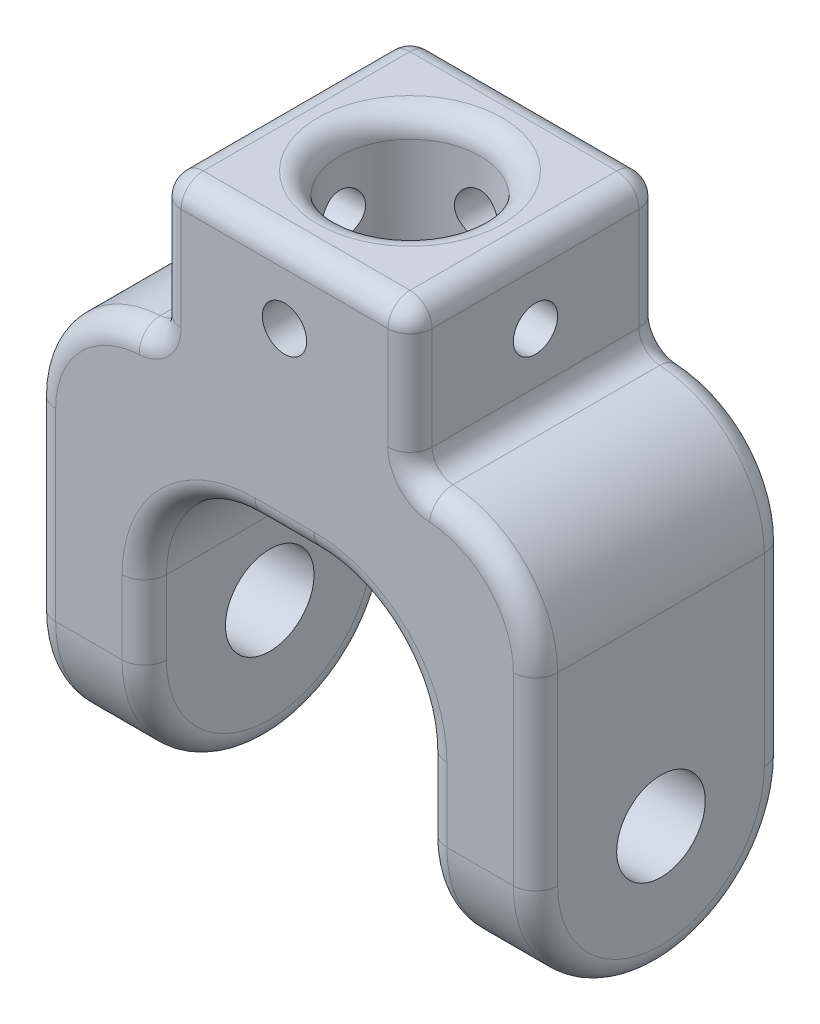
from build123d import *

# Parameters (mm, degrees)
Y_KSEKLIK_EKSTR_ZYON2_DEPTH = 17
IZIM2_R                     = 9.5
KES_EKSTR_ZYON1_DEPTH       = 77.866068747
KES_EKSTR_ZYON2_DEPTH       = 69
IZIM4_R                     = 6
KES_EKSTR_ZYON3_DEPTH       = 69
IZIM5_R                     = 3
KES_EKSTR_ZYON4_DEPTH       = 52
IZIM6_R                     = 3
KES_EKSTR_ZYON5_DEPTH       = 35.0000001
RADYUS1_R                   = 3


with BuildPart() as part:
    # Çizim1 → Yükseklik-Ekstrüzyon2 (new body, symmetric)
    with BuildSketch(Plane.XY):
        with BuildLine():
            Line((-19, -42), (-34, -42))
            Line((-34, -42), (-34, 0))
            ThreePointArc((-34, 0), (-28.874208829, 11.291589791), (-17, 14.866068747))
            Line((-17, 14.866068747), (-17, 34.866068747))
            Line((-17, 34.866068747), (17, 34.866068747))
            Line((17, 34.866068747), (17, 14.866068747))
            ThreePointArc((17, 14.866068747), (28.874208829, 11.291589791), (34, 0))
            Line((34, 0), (34, -42))
            Line((34, -42), (19, -42))
            Line((19, -42), (19, -15))
            ThreePointArc((19, -15), (14.606601718, -4.393398282), (4, 0))
            Line((4, 0), (-4, 0))
            ThreePointArc((-4, 0), (-14.606601718, -4.393398282), (-19, -15))
            Line((-19, -15), (-19, -42))
        make_face()
    extrude(amount=Y_KSEKLIK_EKSTR_ZYON2_DEPTH, both=True)

    # Çizim2 → Kes-Ekstrüzyon1 (cut, through all)
    with BuildSketch(Plane(origin=(0, 34.866068747, 0), x_dir=(1, 0, 0), z_dir=(0, 1, 0))):
        Circle(IZIM2_R)
    extrude(amount=-KES_EKSTR_ZYON1_DEPTH, mode=Mode.SUBTRACT)

    # Çizim3 → Kes-Ekstrüzyon2 (cut, through all)
    with BuildSketch(Plane.ZY.offset(34)):
        with BuildLine():
            ThreePointArc((0, -42), (-12.02081528, -37.02081528), (-17, -25))
            Line((-17, -25), (-17, -42))
            Line((-17, -42), (0, -42))
        make_face()
        with BuildLine():
            Line((17, -42), (17, -25))
            ThreePointArc((17, -25), (12.02081528, -37.02081528), (0, -42))
            Line((0, -42), (17, -42))
        make_face()
    extrude(amount=-KES_EKSTR_ZYON2_DEPTH, mode=Mode.SUBTRACT)

    # Çizim4 → Kes-Ekstrüzyon3 (cut, through all)
    with BuildSketch(Plane.ZY.offset(34)):
        with Locations((0, -25)):
            Circle(IZIM4_R)
    extrude(amount=-KES_EKSTR_ZYON3_DEPTH, mode=Mode.SUBTRACT)

    # Çizim5 → Kes-Ekstrüzyon4 (cut, through all)
    with BuildSketch(Plane(origin=(17, 0, 0), x_dir=(0, 0, -1), z_dir=(1, 0, 0))):
        with Locations((0, 24.866068747)):
            Circle(IZIM5_R)
    extrude(amount=-KES_EKSTR_ZYON4_DEPTH, mode=Mode.SUBTRACT)

    # Çizim6 → Kes-Ekstrüzyon5 (cut, through all)
    with BuildSketch(Plane.XY.offset(17)):
        with Locations((0, 24.866068747)):
            Circle(IZIM6_R)
    extrude(amount=-KES_EKSTR_ZYON5_DEPTH, mode=Mode.SUBTRACT)

    # Radyus1
    radyus1_edges = [part.edges().sort_by_distance(p)[0] for p in [
        (0, 0, 17),
        (-34, -12.5, -17),
        (-28.874208829, 11.291589791, -17),
        (-17, 24.866068747, -17),
        (0, 34.866068747, -17),
        (17, 24.866068747, -17),
        (28.874208829, 11.291589791, -17),
        (14.606601718, -4.393398282, 17),
        (19, -20, -17),
        (14.606601718, -4.393398282, -17),
        (0, 0, -17),
        (-14.606601718, -4.393398282, -17),
        (19, -20, 17),
        (-17, 14.866068747, 0),
        (-17, 34.866068747, 0),
        (17, 34.866068747, 0),
        (17, 14.866068747, 0),
        (28.874208829, 11.291589791, 17),
        (17, 24.866068747, 17),
        (0, 34.866068747, 17),
        (-17, 24.866068747, 17),
        (-9.5, 34.866068747, 0),
        (-28.874208829, 11.291589791, 17),
        (-19, -20, -17),
        (34, -12.5, -17),
        (-34, -12.5, 17),
        (-34, -42, 0),
        (-19, -42, 0),
        (19, -42, 0),
        (34, -42, 0),
        (-19, -20, 17),
        (34, -12.5, 17),
        (-14.606601718, -4.393398282, 17),
    ]]
    fillet(radyus1_edges, radius=RADYUS1_R)


solid = part.part
